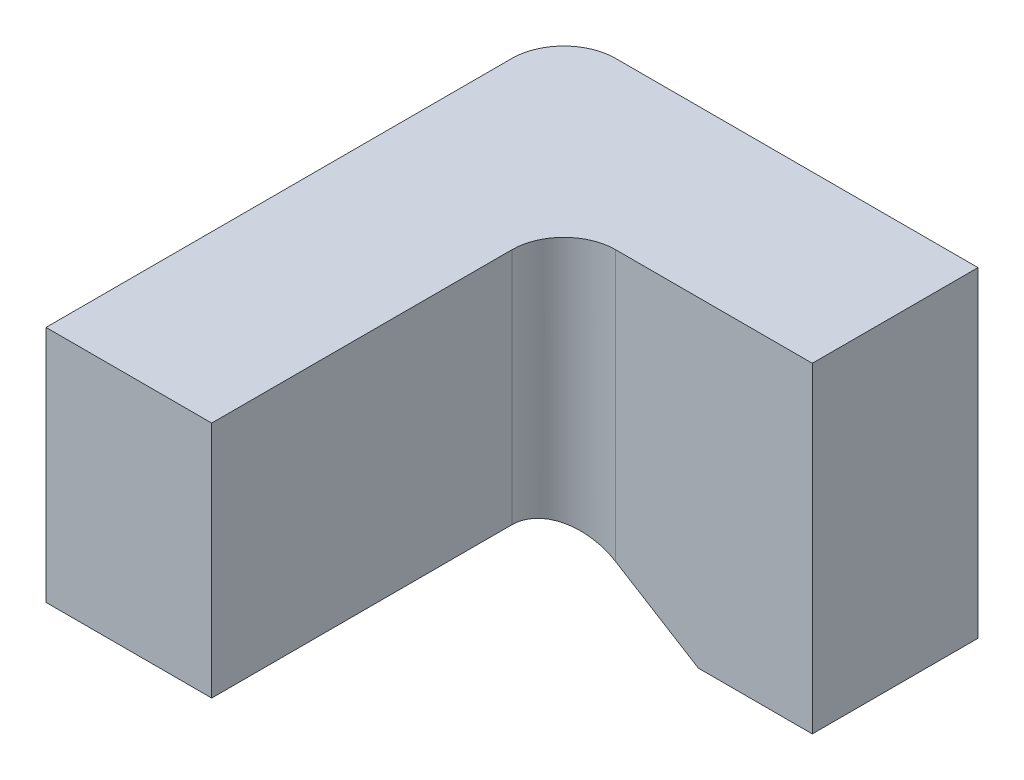
from build123d import *

# Parameters (mm, degrees)
EXTRUDE_1_DEPTH = 0.16
SKETCH_2_W      = 0.16
SKETCH_2_H      = 0.23
EXTRUDE_2_DEPTH = 0.34
FILLET_1_R      = 0.05
FILLET_2_R      = 0.05


with BuildPart() as part:
    # 草图1 → 凸台-拉伸1 (new body)
    with BuildSketch(Plane.XY):
        Polygon((0, 0), (0.4, 0), (0.4, -0.31), (0.29, -0.31), (0.16, -0.23), (0, -0.23), align=None)
    extrude(amount=EXTRUDE_1_DEPTH)

    # 草图2 → 凸台-拉伸2 (add)
    with BuildSketch(Plane.XY.offset(0.16)):
        with Locations((0.08, -0.115)):
            Rectangle(SKETCH_2_W, SKETCH_2_H)
    extrude(amount=EXTRUDE_2_DEPTH)

    # 圆角1
    fillet_1_edges = [part.edges().sort_by_distance(p)[0] for p in [
        (0, -0.115, 0),
    ]]
    fillet(fillet_1_edges, radius=FILLET_1_R)

    # 圆角2
    fillet_2_edges = [part.edges().sort_by_distance(p)[0] for p in [
        (0.16, -0.115, 0.16),
    ]]
    fillet(fillet_2_edges, radius=FILLET_2_R)


solid = part.part
